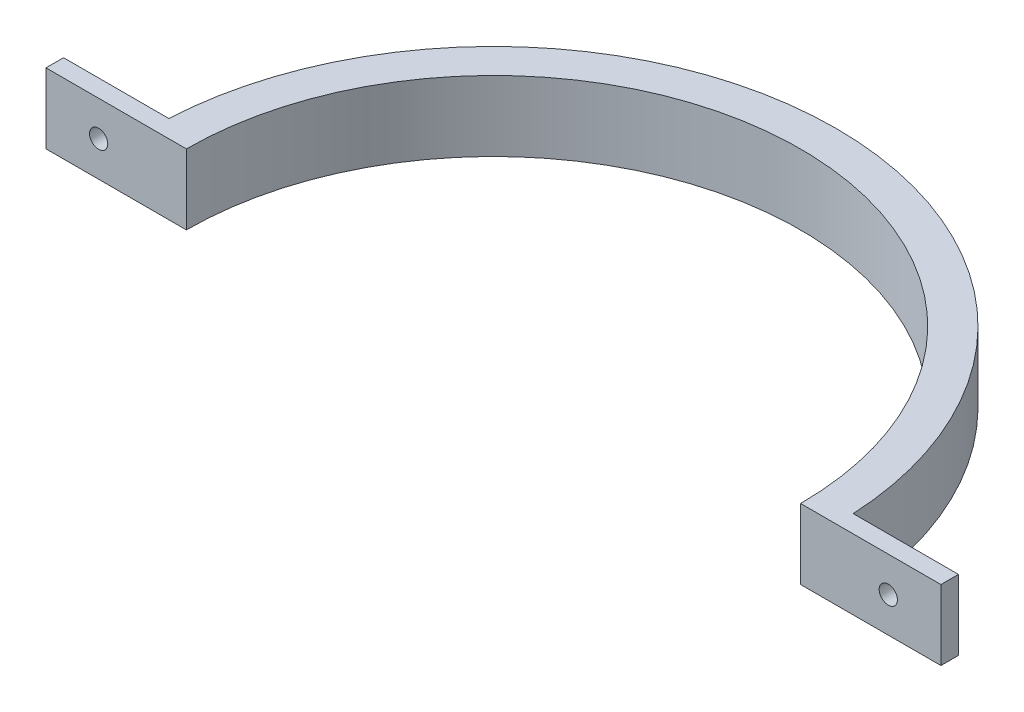
from build123d import *

# Parameters (mm, degrees)
BOSS_EXTRUDE1_DEPTH = 12.7
SKETCH5_R           = 1.651
CUT_EXTRUDE1_DEPTH  = 4.175


with BuildPart() as part:
    # Sketch1 → Boss-Extrude1 (new body)
    with BuildSketch(Plane(origin=(0, 0, 0), x_dir=(1, 0, 0), z_dir=(0, 1, 0))):
        with BuildLine():
            Line((-55.5625, 0), (-80.9625, 0))
            Line((-80.9625, 0), (-80.9625, 3.175))
            Line((-80.9625, 3.175), (-61.9125, 3.175))
            ThreePointArc((-61.9125, 3.175), (0, 61.993856803), (61.9125, 3.175))
            Line((61.9125, 3.175), (80.9625, 3.175))
            Line((80.9625, 3.175), (80.9625, 0))
            Line((80.9625, 0), (55.5625, 0))
            ThreePointArc((55.5625, 0), (0, 55.5625), (-55.5625, 0))
        make_face()
    extrude(amount=BOSS_EXTRUDE1_DEPTH)

    # Sketch5 → Cut-Extrude1 (cut, through all)
    with BuildSketch(Plane(origin=(0, 0, -3.175), x_dir=(-1, 0, 0), z_dir=(0, 0, -1))):
        with Locations((71.4375, 6.35)):
            Circle(SKETCH5_R)
    cut_extrude1 = extrude(amount=-CUT_EXTRUDE1_DEPTH, mode=Mode.SUBTRACT)

    # Mirror1: Cut-Extrude1 across plane
    add(cut_extrude1.mirror(Plane(origin=(0, 0, 0), x_dir=(0, 0, 1), z_dir=(1, 0, 0))), mode=Mode.SUBTRACT)


solid = part.part
